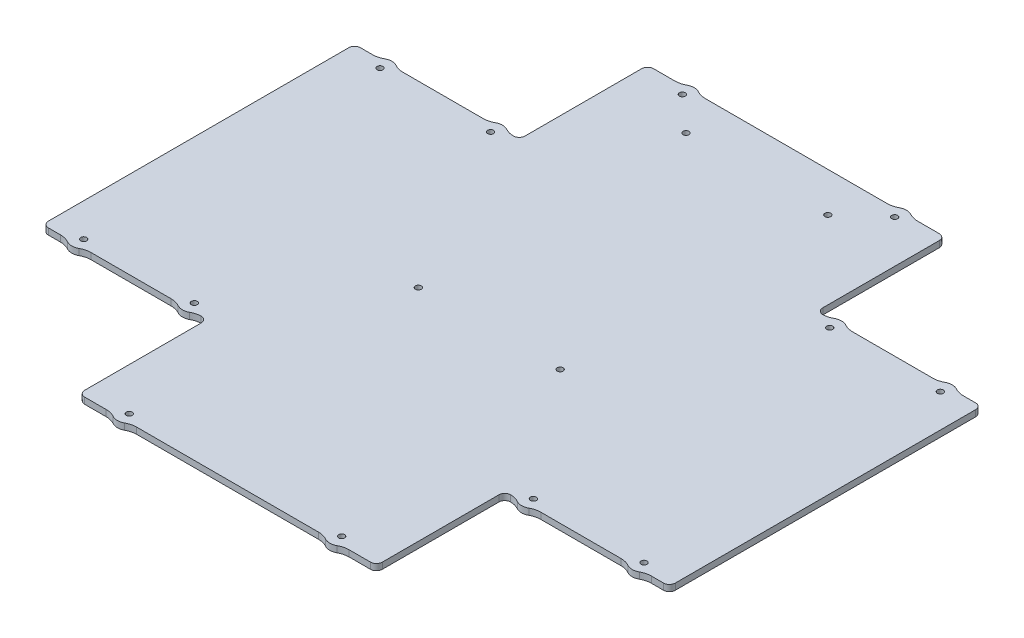
from build123d import *

# Parameters (mm, degrees)
SKETCH1_R           = 1.5
BOSS_EXTRUDE1_DEPTH = 3.175


with BuildPart() as part:
    # Sketch1 → Boss-Extrude1 (new body)
    with BuildSketch(Plane(origin=(0, 3.175, 0), x_dir=(1, 0, 0), z_dir=(0, 1, 0))):
        with BuildLine():
            Line((93.595966692, -79), (134.104033308, -79))
            ThreePointArc((134.104033308, -79), (136.604033308, -79.317541634), (138.945262491, -80.25))
            ThreePointArc((138.945262491, -80.25), (141.85, -81), (144.754737509, -80.25))
            ThreePointArc((144.754737509, -80.25), (147.095966692, -79.317541634), (149.595966692, -79))
            Line((149.595966692, -79), (155.7, -79))
            ThreePointArc((155.7, -79), (157.821320344, -78.121320344), (158.7, -76))
            Line((158.7, -76), (158.7, 76))
            ThreePointArc((158.7, 76), (157.821320344, 78.121320344), (155.7, 79))
            Line((155.7, 79), (149.595966692, 79))
            ThreePointArc((149.595966692, 79), (147.095966692, 79.317541634), (144.754737509, 80.25))
            ThreePointArc((144.754737509, 80.25), (141.85, 81), (138.945262491, 80.25))
            ThreePointArc((138.945262491, 80.25), (136.604033308, 79.317541634), (134.104033308, 79))
            Line((134.104033308, 79), (93.595966692, 79))
            ThreePointArc((93.595966692, 79), (91.095966692, 79.317541635), (88.754737509, 80.25))
            ThreePointArc((88.754737509, 80.25), (85.848773537, 80.999999875), (82.943116423, 80.248812044))
            ThreePointArc((82.943116423, 80.248812044), (80.721943339, 79.347140385), (78.350000001, 79))
            ThreePointArc((78.350000001, 79), (76.228679657, 79.878679657), (75.35, 82))
            Line((75.35, 82), (75.35, 141))
            ThreePointArc((75.35, 141), (74.471320344, 143.121320344), (72.35, 144))
            Line((72.35, 144), (61.495966692, 144))
            ThreePointArc((61.495966692, 144), (58.995966692, 144.317541635), (56.65473751, 145.25))
            ThreePointArc((56.65473751, 145.25), (53.75, 146), (50.845262491, 145.25))
            ThreePointArc((50.845262491, 145.25), (48.504033308, 144.317541635), (46.004033308, 144))
            Line((46.004033308, 144), (-46.004033308, 144))
            ThreePointArc((-46.004033308, 144), (-48.504033308, 144.317541635), (-50.84526249, 145.25))
            ThreePointArc((-50.84526249, 145.25), (-53.75, 146), (-56.654737509, 145.25))
            ThreePointArc((-56.654737509, 145.25), (-58.995966692, 144.317541635), (-61.495966692, 144))
            Line((-61.495966692, 144), (-72.35, 144))
            ThreePointArc((-72.35, 144), (-74.471320344, 143.121320344), (-75.35, 141))
            Line((-75.35, 141), (-75.35, 82))
            ThreePointArc((-75.35, 82), (-76.228679657, 79.878679655), (-78.350000003, 79))
            ThreePointArc((-78.350000003, 79), (-80.72194334, 79.347140385), (-82.943116423, 80.248812044))
            ThreePointArc((-82.943116423, 80.248812044), (-85.848773537, 80.999999874), (-88.754737509, 80.25))
            ThreePointArc((-88.754737509, 80.25), (-91.095966692, 79.317541634), (-93.595966692, 79))
            Line((-93.595966692, 79), (-134.104033308, 79))
            ThreePointArc((-134.104033308, 79), (-136.604033308, 79.317541634), (-138.945262491, 80.25))
            ThreePointArc((-138.945262491, 80.25), (-141.85, 81), (-144.754737509, 80.25))
            ThreePointArc((-144.754737509, 80.25), (-147.095966692, 79.317541634), (-149.595966692, 79))
            Line((-149.595966692, 79), (-155.7, 79))
            ThreePointArc((-155.7, 79), (-157.821320344, 78.121320344), (-158.7, 76))
            Line((-158.7, 76), (-158.7, -76))
            ThreePointArc((-158.7, -76), (-157.821320344, -78.121320344), (-155.7, -79))
            Line((-155.7, -79), (-149.595966692, -79))
            ThreePointArc((-149.595966692, -79), (-147.095966692, -79.317541634), (-144.754737509, -80.25))
            ThreePointArc((-144.754737509, -80.25), (-141.85, -81), (-138.945262491, -80.25))
            ThreePointArc((-138.945262491, -80.25), (-136.604033308, -79.317541634), (-134.104033308, -79))
            Line((-134.104033308, -79), (-93.595966692, -79))
            ThreePointArc((-93.595966692, -79), (-91.095966692, -79.317541634), (-88.754737509, -80.25))
            ThreePointArc((-88.754737509, -80.25), (-85.848773537, -80.999999874), (-82.943116423, -80.248812044))
            ThreePointArc((-82.943116423, -80.248812044), (-80.721943339, -79.347140385), (-78.350000001, -79))
            ThreePointArc((-78.350000001, -79), (-76.228679657, -79.878679656), (-75.35, -82))
            Line((-75.35, -82), (-75.35, -141))
            ThreePointArc((-75.35, -141), (-74.471320344, -143.121320343), (-72.35, -144))
            Line((-72.35, -144), (-61.495966692, -144))
            ThreePointArc((-61.495966692, -144), (-58.995966692, -144.317541634), (-56.654737509, -145.25))
            ThreePointArc((-56.654737509, -145.25), (-53.75, -145.999999999), (-50.84526249, -145.25))
            ThreePointArc((-50.84526249, -145.25), (-48.504033308, -144.317541634), (-46.004033308, -144))
            Line((-46.004033308, -144), (46.004033308, -144))
            ThreePointArc((46.004033308, -144), (48.504033308, -144.317541634), (50.845262491, -145.25))
            ThreePointArc((50.845262491, -145.25), (53.75, -145.999999999), (56.65473751, -145.25))
            ThreePointArc((56.65473751, -145.25), (58.995966692, -144.317541634), (61.495966692, -144))
            Line((61.495966692, -144), (72.35, -144))
            ThreePointArc((72.35, -144), (74.471320344, -143.121320343), (75.35, -141))
            Line((75.35, -141), (75.35, -82))
            ThreePointArc((75.35, -82), (76.228679656, -79.878679656), (78.35, -79))
            ThreePointArc((78.35, -79), (80.721943339, -79.347140384), (82.943116423, -80.248812044))
            ThreePointArc((82.943116423, -80.248812044), (85.848773537, -80.999999874), (88.754737509, -80.25))
            ThreePointArc((88.754737509, -80.25), (91.095966692, -79.317541634), (93.595966692, -79))
        make_face()
        with Locations((141.85, -75)):
            Circle(SKETCH1_R, mode=Mode.SUBTRACT)
        with Locations((85.85, -75)):
            Circle(SKETCH1_R, mode=Mode.SUBTRACT)
        with Locations((53.75, -140)):
            Circle(SKETCH1_R, mode=Mode.SUBTRACT)
        with Locations((-53.75, -140)):
            Circle(SKETCH1_R, mode=Mode.SUBTRACT)
        with Locations((-85.85, -75)):
            Circle(SKETCH1_R, mode=Mode.SUBTRACT)
        with Locations((-141.85, -75)):
            Circle(SKETCH1_R, mode=Mode.SUBTRACT)
        with Locations((141.85, 75)):
            Circle(SKETCH1_R, mode=Mode.SUBTRACT)
        with Locations((85.849999999, 75)):
            Circle(SKETCH1_R, mode=Mode.SUBTRACT)
        with Locations((53.75, 140)):
            Circle(SKETCH1_R, mode=Mode.SUBTRACT)
        with Locations((-53.75, 140)):
            Circle(SKETCH1_R, mode=Mode.SUBTRACT)
        with Locations((-85.85, 75)):
            Circle(SKETCH1_R, mode=Mode.SUBTRACT)
        with Locations((-141.85, 75)):
            Circle(SKETCH1_R, mode=Mode.SUBTRACT)
        with Locations((-35.9, 124)):
            Circle(SKETCH1_R, mode=Mode.SUBTRACT)
        with Locations((35.9, 124)):
            Circle(SKETCH1_R, mode=Mode.SUBTRACT)
        with Locations((-35.9, -11.5)):
            Circle(SKETCH1_R, mode=Mode.SUBTRACT)
        with Locations((35.9, -11.5)):
            Circle(SKETCH1_R, mode=Mode.SUBTRACT)
    extrude(amount=-BOSS_EXTRUDE1_DEPTH)


solid = part.part
